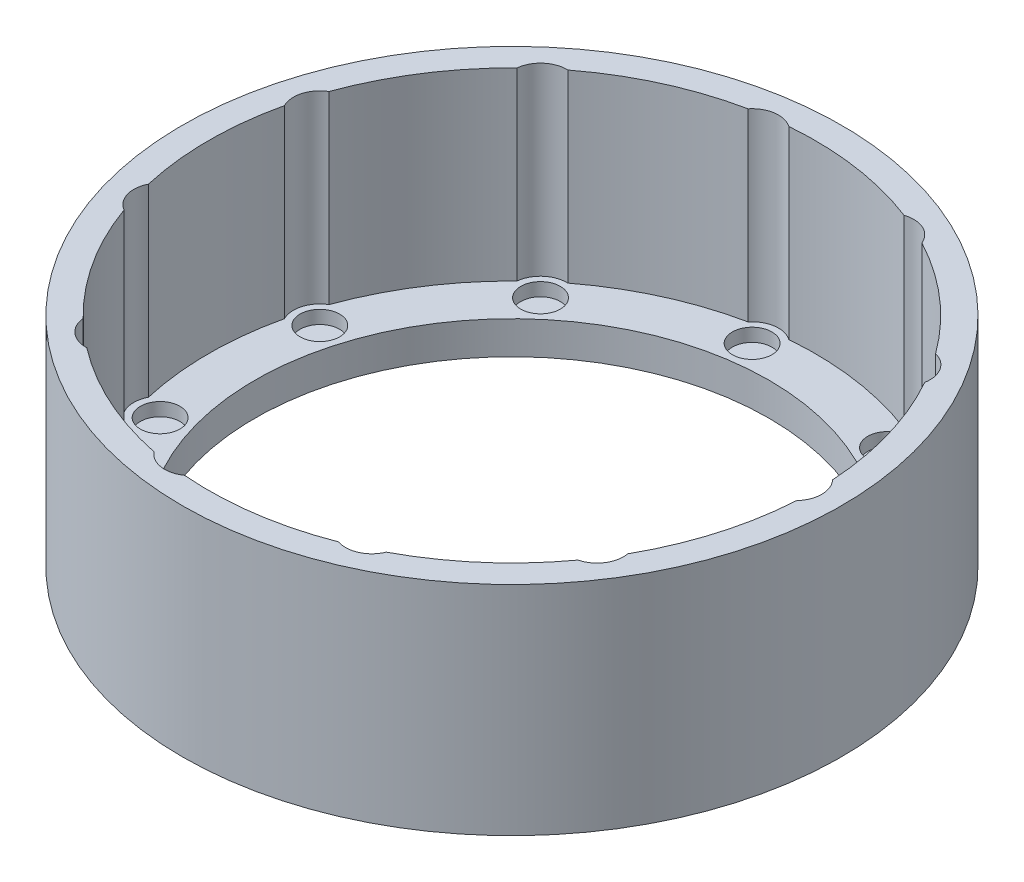
from build123d import *

# Parameters (mm, degrees)
SKETCH1_R           = 50
BOSS_EXTRUDE1_DEPTH = 5
SKETCH2_R           = 2.5
BOSS_EXTRUDE2_DEPTH = 30
SKETCH3_R           = 50
BOSS_EXTRUDE3_DEPTH = 28
SKETCH4_R           = 39
CUT_EXTRUDE1_DEPTH  = 6
SKETCH5_R           = 3
CUT_EXTRUDE2_DEPTH  = 44
SKETCH6_R           = 50
SKETCH6_R_2         = 39
BOSS_EXTRUDE4_DEPTH = 3


with BuildPart() as part:
    # Sketch1 → Boss-Extrude1 (new body)
    with BuildSketch(Plane(origin=(0, 0, 0), x_dir=(1, 0, 0), z_dir=(0, 1, 0))):
        Circle(SKETCH1_R)
    extrude(amount=BOSS_EXTRUDE1_DEPTH)

    # Sketch2 → Boss-Extrude2 (add)
    with BuildSketch(Plane(origin=(0, 5, 0), x_dir=(1, 0, 0), z_dir=(0, 1, 0))):
        with Locations((43, 0)):
            Circle(SKETCH2_R)
        with Locations((36.173901912, -23.247555151)):
            Circle(SKETCH2_R)
        with Locations((17.862845559, -39.1141758)):
            Circle(SKETCH2_R)
        with Locations((-6.119538046, -42.562322001)):
            Circle(SKETCH2_R)
        with Locations((-28.15901156, -32.497231697)):
            Circle(SKETCH2_R)
        with Locations((-41.258197865, -12.114499944)):
            Circle(SKETCH2_R)
        with Locations((-41.258197865, 12.114499944)):
            Circle(SKETCH2_R)
        with Locations((-28.15901156, 32.497231697)):
            Circle(SKETCH2_R)
        with Locations((-6.119538046, 42.562322001)):
            Circle(SKETCH2_R)
        with Locations((17.862845559, 39.1141758)):
            Circle(SKETCH2_R)
        with Locations((36.173901912, 23.247555151)):
            Circle(SKETCH2_R)
    extrude(amount=BOSS_EXTRUDE2_DEPTH)

    # Sketch3 → Boss-Extrude3 (add)
    with BuildSketch(Plane(origin=(0, 5, 0), x_dir=(1, 0, 0), z_dir=(0, 1, 0))):
        Circle(SKETCH3_R)
        with BuildLine():
            ThreePointArc((45.918604651, -2.735278211), (47, 0), (45.918604651, 2.735278211))
            ThreePointArc((45.918604651, 2.735278211), (44.136676786, 12.959697615), (40.107991433, 22.524409497))
            ThreePointArc((40.107991433, 22.524409497), (39.538916043, 25.41011842), (37.150385338, 27.126534413))
            ThreePointArc((37.150385338, 27.126534413), (30.123593761, 34.76448042), (21.563374325, 40.632756339))
            ThreePointArc((21.563374325, 40.632756339), (19.524505611, 42.752703782), (16.587181171, 42.905307606))
            ThreePointArc((16.587181171, 42.905307606), (6.546482561, 45.531786327), (-3.827461772, 45.840490141))
            ThreePointArc((-3.827461772, 45.840490141), (-6.688797399, 46.521607768), (-9.242335817, 45.061948789))
            ThreePointArc((-9.242335817, 45.061948789), (-19.109090598, 41.843071786), (-28.0031058, 36.494192217))
            ThreePointArc((-28.0031058, 36.494192217), (-30.778454495, 35.520229995), (-32.137476487, 32.911739623))
            ThreePointArc((-32.137476487, 32.911739623), (-38.69766251, 24.869477603), (-43.287961597, 15.561246119))
            ThreePointArc((-43.287961597, 15.561246119), (-45.09616976, 13.241430172), (-44.829195445, 10.312285671))
            ThreePointArc((-44.829195445, 10.312285671), (-46, 0), (-44.829195445, -10.312285671))
            ThreePointArc((-44.829195445, -10.312285671), (-45.09616976, -13.241430172), (-43.287961597, -15.561246119))
            ThreePointArc((-43.287961597, -15.561246119), (-38.69766251, -24.869477603), (-32.137476487, -32.911739623))
            ThreePointArc((-32.137476487, -32.911739623), (-30.778454495, -35.520229995), (-28.0031058, -36.494192217))
            ThreePointArc((-28.0031058, -36.494192217), (-19.109090598, -41.843071786), (-9.242335817, -45.061948789))
            ThreePointArc((-9.242335817, -45.061948789), (-6.688797399, -46.521607768), (-3.827461772, -45.840490141))
            ThreePointArc((-3.827461772, -45.840490141), (6.546482561, -45.531786327), (16.587181171, -42.905307606))
            ThreePointArc((16.587181171, -42.905307606), (19.524505611, -42.752703782), (21.563374325, -40.632756339))
            ThreePointArc((21.563374325, -40.632756339), (30.123593761, -34.76448042), (37.150385338, -27.126534413))
            ThreePointArc((37.150385338, -27.126534413), (39.538916043, -25.41011842), (40.107991433, -22.524409497))
            ThreePointArc((40.107991433, -22.524409497), (44.136676786, -12.959697615), (45.918604651, -2.735278211))
        make_face(mode=Mode.SUBTRACT)
    extrude(amount=BOSS_EXTRUDE3_DEPTH)

    # Sketch4 → Cut-Extrude1 (cut)
    with BuildSketch(Plane(origin=(0, 5, 0), x_dir=(1, 0, 0), z_dir=(0, 1, 0))):
        Circle(SKETCH4_R)
    extrude(amount=-CUT_EXTRUDE1_DEPTH, mode=Mode.SUBTRACT)

    # Sketch5 → Cut-Extrude2 (cut, symmetric)
    with BuildSketch(Plane(origin=(0, 5, 0), x_dir=(1, 0, 0), z_dir=(0, 1, 0))):
        with Locations((43, 0)):
            Circle(SKETCH5_R)
        with Locations((36.173901912, -23.247555151)):
            Circle(SKETCH5_R)
        with Locations((17.862845559, -39.1141758)):
            Circle(SKETCH5_R)
        with Locations((-6.119538046, -42.562322001)):
            Circle(SKETCH5_R)
        with Locations((-28.15901156, -32.497231697)):
            Circle(SKETCH5_R)
        with Locations((-41.258197865, -12.114499944)):
            Circle(SKETCH5_R)
        with Locations((-41.258197865, 12.114499944)):
            Circle(SKETCH5_R)
        with Locations((-28.15901156, 32.497231697)):
            Circle(SKETCH5_R)
        with Locations((-6.119538046, 42.562322001)):
            Circle(SKETCH5_R)
        with Locations((17.862845559, 39.1141758)):
            Circle(SKETCH5_R)
        with Locations((36.173901912, 23.247555151)):
            Circle(SKETCH5_R)
    extrude(amount=CUT_EXTRUDE2_DEPTH, both=True, mode=Mode.SUBTRACT)

    # Sketch6 → Boss-Extrude4 (add)
    with BuildSketch(Plane.XZ):
        Circle(SKETCH6_R)
        Circle(SKETCH6_R_2, mode=Mode.SUBTRACT)
    extrude(amount=-BOSS_EXTRUDE4_DEPTH)


solid = part.part
